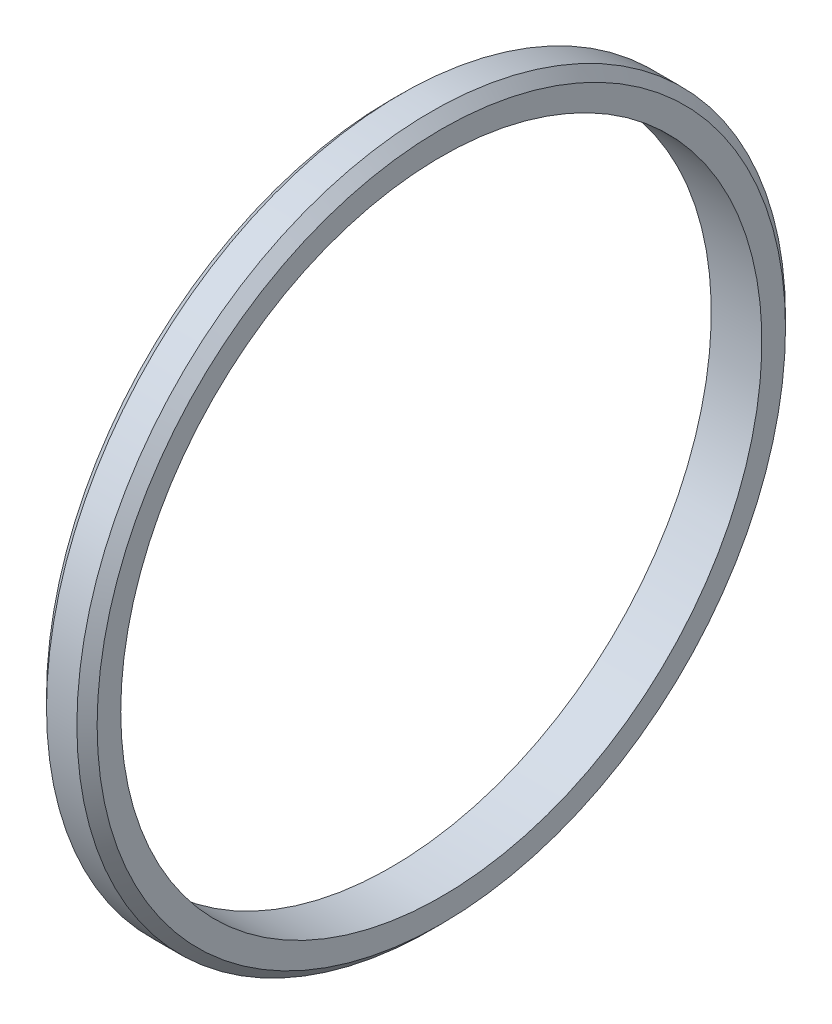
from build123d import *

# Parameters (mm, degrees)
SKETCH_1_W     = 3
SKETCH_1_H     = 2
CHAMFER_1_SIZE = 0.6


with BuildPart() as part:
    # Эскиз1 → Повернуть1 (revolve)
    with BuildSketch(Plane.XY):
        with Locations((1.5, 20)):
            Rectangle(SKETCH_1_W, SKETCH_1_H)
    revolve(axis=Axis((0, 0, 0), (1, 0, 0)))

    # Фаска1
    chamfer_1_edges = [part.edges().sort_by_distance(p)[0] for p in [
        (0, -21, 0),
        (3, -21, 0),
    ]]
    chamfer(chamfer_1_edges, length=CHAMFER_1_SIZE)


solid = part.part
